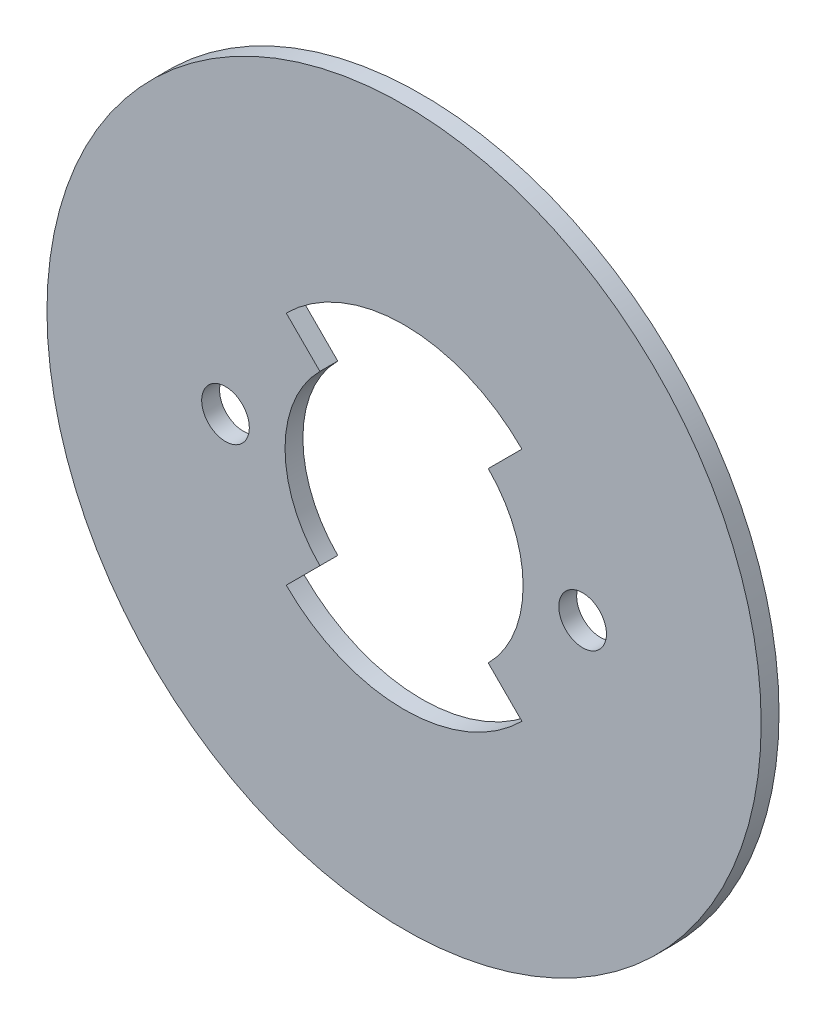
from build123d import *

# Parameters (mm, degrees)
SKETCH1_R           = 30
SKETCH1_R_2         = 2
BOSS_EXTRUDE1_DEPTH = 1.5
CUT_EXTRUDE1_DEPTH  = 10


with BuildPart() as part:
    # Sketch1 → Boss-Extrude1 (new body)
    with BuildSketch(Plane.XY):
        Circle(SKETCH1_R)
        with Locations((15, 0)):
            Circle(SKETCH1_R_2, mode=Mode.SUBTRACT)
        with Locations((-15, 0)):
            Circle(SKETCH1_R_2, mode=Mode.SUBTRACT)
    extrude(amount=BOSS_EXTRUDE1_DEPTH)

    # Sketch2 → Cut-Extrude1 (cut)
    with BuildSketch(Plane(origin=(0, 0, 0), x_dir=(-1, 0, 0), z_dir=(0, 0, -1))):
        with BuildLine():
            Line((7.071067812, 7.071067812), (9.899494937, 9.899494937))
            ThreePointArc((9.899494937, 9.899494937), (0, 14), (-9.899494937, 9.899494937))
            Line((-9.899494937, 9.899494937), (-7.071067812, 7.071067812))
            ThreePointArc((-7.071067812, 7.071067812), (-10, 0), (-7.071067812, -7.071067812))
            Line((-7.071067812, -7.071067812), (-9.899494937, -9.899494937))
            ThreePointArc((-9.899494937, -9.899494937), (0, -14), (9.899494937, -9.899494937))
            Line((9.899494937, -9.899494937), (7.071067812, -7.071067812))
            ThreePointArc((7.071067812, -7.071067812), (10, 0), (7.071067812, 7.071067812))
        make_face()
    extrude(amount=-CUT_EXTRUDE1_DEPTH, mode=Mode.SUBTRACT)


solid = part.part
